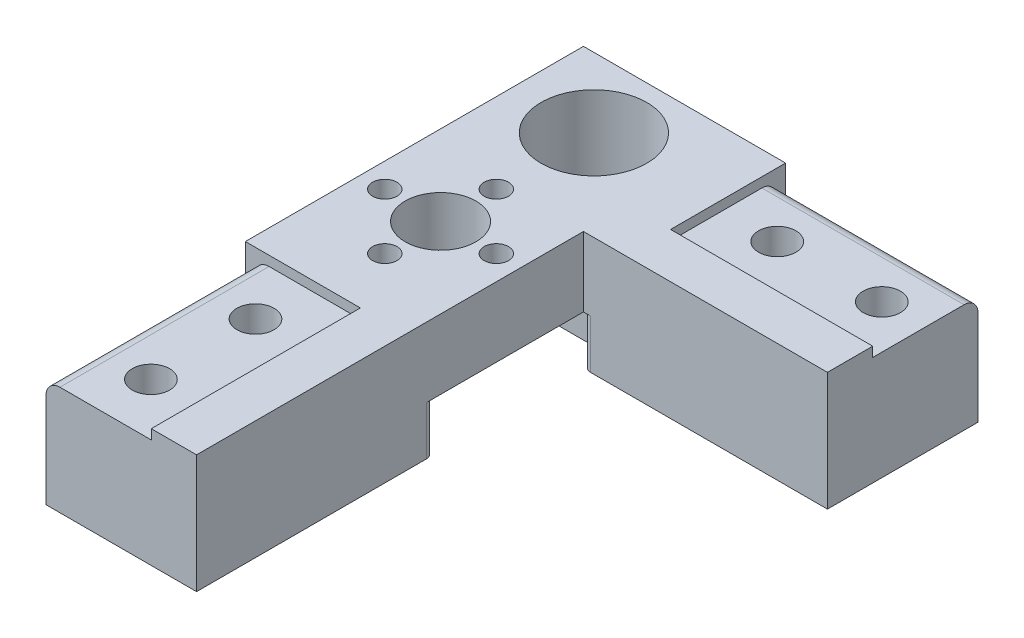
from build123d import *

# Parameters (mm, degrees)
SALIENTE_EXTRUIR2_DEPTH = 17
CROQUIS4_R              = 7.575
CORTAR_EXTRUIR7_DEPTH   = 18
CROQUIS12_R             = 5.075
CORTAR_EXTRUIR12_DEPTH  = 18
CROQUIS17_R             = 1.75
CORTAR_EXTRUIR15_DEPTH  = 18
CORTAR_EXTRUIR9_DEPTH   = 14
CORTAR_EXTRUIR10_DEPTH  = 15
CROQUIS10_R             = 2.675
CORTAR_EXTRUIR11_DEPTH  = 8.6
SALIENTE_EXTRUIR3_DEPTH = 15
SALIENTE_EXTRUIR4_DEPTH = 15
CROQUIS16_R             = 2.675
CORTAR_EXTRUIR14_DEPTH  = 8.6
CROQUIS18_W             = 23
CROQUIS18_H             = 25
CORTAR_EXTRUIR16_DEPTH  = 7
CORTAR_EXTRUIR17_DEPTH  = 2.5
REDONDEO2_R             = 1
REDONDEO4_R             = 2


with BuildPart() as part:
    # Croquis1 → Saliente-Extruir2 (new body)
    with BuildSketch(Plane(origin=(0, 0, 0), x_dir=(1, 0, 0), z_dir=(0, 1, 0))):
        Polygon((23, -63.5), (23, -23), (43, -23), (43, 0), (0, 0), (0, -63.5), align=None)
    extrude(amount=-SALIENTE_EXTRUIR2_DEPTH)

    # Croquis4 → Cortar-Extruir7 (cut, through all)
    with BuildSketch(Plane(origin=(0, 0, 0), x_dir=(-1, 0, 0), z_dir=(0, -1, 0))):
        with Locations((-11.5, -10)):
            Circle(CROQUIS4_R)
    extrude(amount=CORTAR_EXTRUIR7_DEPTH, mode=Mode.SUBTRACT)

    # Croquis12 → Cortar-Extruir12 (cut, through all)
    with BuildSketch(Plane(origin=(0, 0, 0), x_dir=(1, 0, 0), z_dir=(0, 1, 0))):
        with Locations((11.5, -32)):
            Circle(CROQUIS12_R)
    extrude(amount=-CORTAR_EXTRUIR12_DEPTH, mode=Mode.SUBTRACT)

    # Croquis17 → Cortar-Extruir15 (cut, through all)
    with BuildSketch(Plane(origin=(0, 0, 0), x_dir=(1, 0, 0), z_dir=(0, 1, 0))):
        with Locations((11.5, -24)):
            Circle(CROQUIS17_R)
        with Locations((11.5, -40)):
            Circle(CROQUIS17_R)
        with Locations((3.5, -32)):
            Circle(CROQUIS17_R)
        with Locations((19.5, -32)):
            Circle(CROQUIS17_R)
    extrude(amount=-CORTAR_EXTRUIR15_DEPTH, mode=Mode.SUBTRACT)

    # Croquis8 → Cortar-Extruir9 (cut)
    with BuildSketch(Plane(origin=(43, 0, 0), x_dir=(0, 0, -1), z_dir=(1, 0, 0))):
        Polygon((0, -17), (0, 0), (-16.5, 0), (-16.5, -1.4), (-1.4, -1.4), (-1.4, -17), align=None)
    extrude(amount=-CORTAR_EXTRUIR9_DEPTH, mode=Mode.SUBTRACT)

    # Croquis9 → Cortar-Extruir10 (cut)
    with BuildSketch(Plane(origin=(0, 0, 63.5), x_dir=(-1, 0, 0), z_dir=(0, 0, -1))):
        Polygon((0, -17), (-1.4, -17), (-1.4, -1.4), (-16.5, -1.4), (-16.5, 0), (0, 0), align=None)
    extrude(amount=CORTAR_EXTRUIR10_DEPTH, mode=Mode.SUBTRACT)

    # Croquis10 → Cortar-Extruir11 (cut)
    with BuildSketch(Plane(origin=(0, -1.4, 0), x_dir=(1, 0, 0), z_dir=(0, 1, 0))):
        with Locations((36.75, -8.95)):
            Circle(CROQUIS10_R)
        with Locations((8.95, -56)):
            Circle(CROQUIS10_R)
    extrude(amount=-CORTAR_EXTRUIR11_DEPTH, mode=Mode.SUBTRACT)

    # Croquis14 → Saliente-Extruir3 (add)
    with BuildSketch(Plane.XY.offset(63.5)):
        Polygon((23, 0), (16.5, 0), (16.5, -1.4), (1.4, -1.4), (1.4, -17), (23, -17), align=None)
    extrude(amount=SALIENTE_EXTRUIR3_DEPTH)

    # Croquis15 → Saliente-Extruir4 (add)
    with BuildSketch(Plane(origin=(43, 0, 0), x_dir=(0, 0, -1), z_dir=(1, 0, 0))):
        Polygon((-1.4, -17), (-1.4, -1.4), (-16.5, -1.4), (-16.5, 0), (-23, 0), (-23, -17), align=None)
    extrude(amount=SALIENTE_EXTRUIR4_DEPTH)

    # Croquis16 → Cortar-Extruir14 (cut)
    with BuildSketch(Plane(origin=(0, -1.4, 0), x_dir=(1, 0, 0), z_dir=(0, 1, 0))):
        with Locations((8.95, -71)):
            Circle(CROQUIS16_R)
        with Locations((51.75, -8.95)):
            Circle(CROQUIS16_R)
    extrude(amount=-CORTAR_EXTRUIR14_DEPTH, mode=Mode.SUBTRACT)

    # Croquis18 → Cortar-Extruir16 (cut)
    with BuildSketch(Plane.XZ.offset(17)):
        with Locations((11.5, 32)):
            Rectangle(CROQUIS18_W, CROQUIS18_H)
    extrude(amount=-CORTAR_EXTRUIR16_DEPTH, mode=Mode.SUBTRACT)

    # Croquis19 → Cortar-Extruir17 (cut)
    with BuildSketch(Plane.XZ.offset(10)):
        Polygon((14.675426481, 40), (13.08771324, 42.75), (9.91228676, 42.75), (8.324573519, 40), (9.91228676, 37.25), (13.08771324, 37.25), align=None)
        Polygon((22.25, 30.41228676), (22.25, 33.58771324), (19.5, 35.175426481), (16.75, 33.58771324), (16.75, 30.41228676), (19.5, 28.824573519), align=None)
        Polygon((14.675426481, 24), (13.08771324, 26.75), (9.91228676, 26.75), (8.324573519, 24), (9.91228676, 21.25), (13.08771324, 21.25), align=None)
        Polygon((0.75, 33.58771324), (0.75, 30.41228676), (3.5, 28.824573519), (6.25, 30.41228676), (6.25, 33.58771324), (3.5, 35.175426481), align=None)
    extrude(amount=-CORTAR_EXTRUIR17_DEPTH, mode=Mode.SUBTRACT)

    # Redondeo2
    redondeo2_edges = [part.edges().sort_by_distance(p)[0] for p in [
        (23, -13.5, 23),
        (23, -13.5, 44.5),
        (0, -13.5, 44.5),
        (23, -13.5, 19.5),
        (0, -13.5, 19.5),
    ]]
    fillet(redondeo2_edges, radius=REDONDEO2_R)

    # Redondeo4
    redondeo4_edges = [part.edges().sort_by_distance(p)[0] for p in [
        (43.5, -1.4, 1.4),
        (1.4, -1.4, 63.5),
    ]]
    fillet(redondeo4_edges, radius=REDONDEO4_R)


solid = part.part
